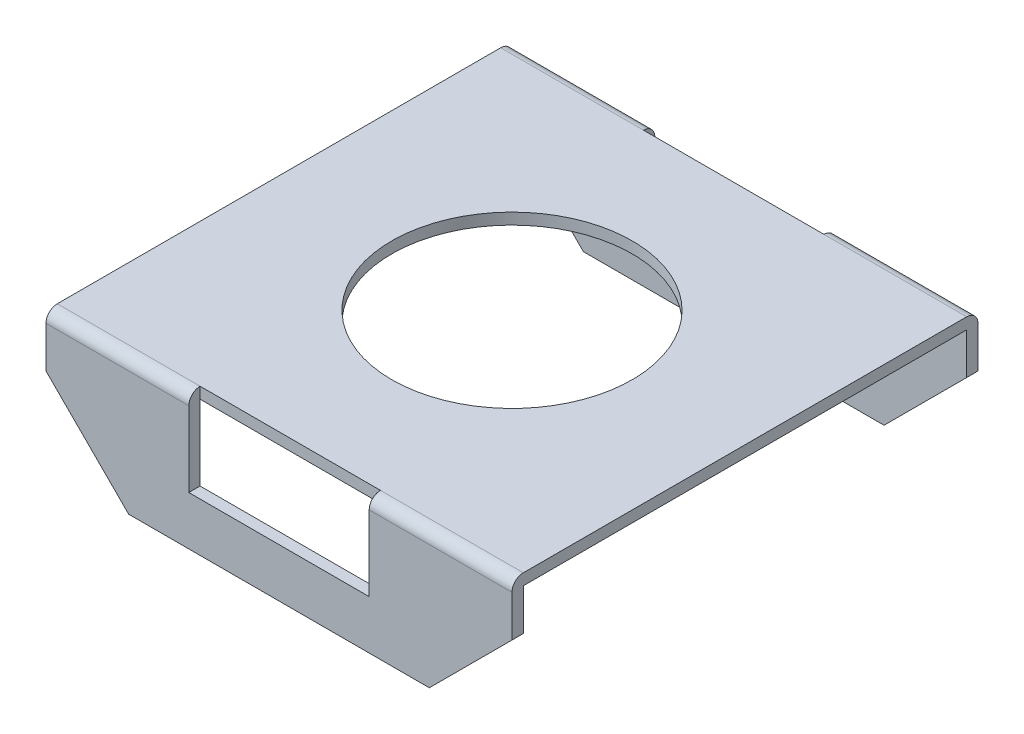
from build123d import *

# Parameters (mm, degrees)
EXTRUDE_THIN3_DEPTH     = 3.1
SKETCH2_W               = 2.4
SKETCH2_H               = 1
CUT_EXTRUDE1_DEPTH      = 4.1
CUT_EXTRUDE1_DEPTH_BACK = 4.1
SKETCH3_W               = 2.4
SKETCH3_H               = 0.15
CUT_EXTRUDE2_DEPTH      = 1
FILLET1_R               = 0.15
SKETCH4_R               = 1.6
CUT_EXTRUDE3_DEPTH      = 1


with BuildPart() as part:
    # Sketch1 → Extrude-Thin3 (new body, symmetric)
    with BuildSketch(Plane(origin=(0, 0, 0), x_dir=(0, 0, -1), z_dir=(1, 0, 0))):
        Polygon((-3.1, 0.2), (-3.1, 2), (3.1, 2), (3.1, 0.2), (2.95, 0.2), (2.95, 1.85), (-2.95, 1.85), (-2.95, 0.2), align=None)
    extrude(amount=EXTRUDE_THIN3_DEPTH, both=True)

    # Sketch2 → Cut-Extrude1 (cut, two sides)
    with BuildSketch(Plane.XY) as cut_extrude1_sk:
        with Locations((0, 1.35)):
            Rectangle(SKETCH2_W, SKETCH2_H)
        Polygon((-3.1, 1.3), (-2, 0.2), (-3.1, 0.2), align=None)
        Polygon((3.1, 0.2), (3.1, 1.3), (2, 0.2), align=None)
    extrude(amount=CUT_EXTRUDE1_DEPTH, mode=Mode.SUBTRACT)
    extrude(cut_extrude1_sk.sketch, amount=-CUT_EXTRUDE1_DEPTH_BACK, mode=Mode.SUBTRACT)

    # Sketch3 → Cut-Extrude2 (cut)
    with BuildSketch(Plane(origin=(0, 2, 0), x_dir=(1, 0, 0), z_dir=(0, 1, 0))):
        with Locations((0, 3.025)):
            Rectangle(SKETCH3_W, SKETCH3_H)
        with Locations((0, -3.025)):
            Rectangle(SKETCH3_W, SKETCH3_H)
    extrude(amount=-CUT_EXTRUDE2_DEPTH, mode=Mode.SUBTRACT)

    # Fillet1
    fillet1_edges = [part.edges().sort_by_distance(p)[0] for p in [
        (-2.15, 2, -3.1),
        (2.15, 2, -3.1),
        (-2.15, 2, 3.1),
        (2.15, 2, 3.1),
    ]]
    fillet(fillet1_edges, radius=FILLET1_R)

    # Sketch4 → Cut-Extrude3 (cut)
    with BuildSketch(Plane(origin=(0, 2, 0), x_dir=(1, 0, 0), z_dir=(0, 1, 0))):
        Circle(SKETCH4_R)
    extrude(amount=-CUT_EXTRUDE3_DEPTH, mode=Mode.SUBTRACT)


solid = part.part
